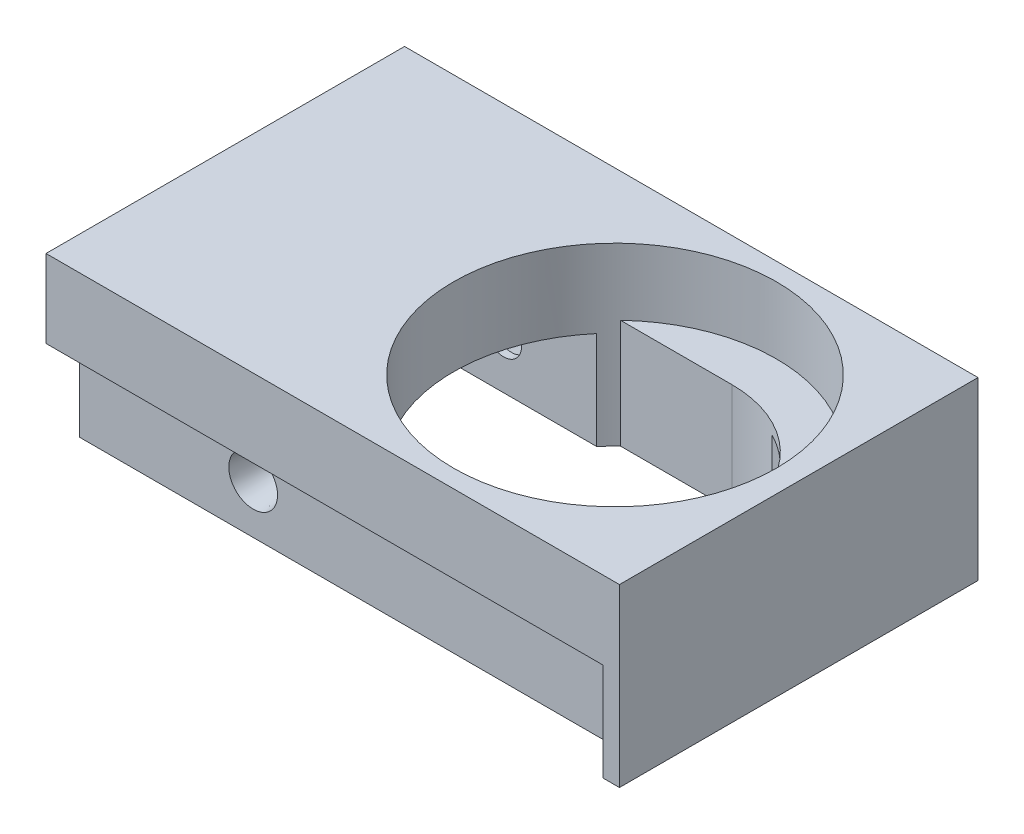
from build123d import *

# Parameters (mm, degrees)
SKETCH1_R               = 13.335
BOSS_EXTRUDE1_DEPTH     = 11.16076
SKETCH3_W               = 63.5
SKETCH3_H               = 40.894
SKETCH3_R               = 13.335
BOSS_EXTRUDE4_DEPTH     = 1.27
BOSS_EXTRUDE5_START     = 1.27
SKETCH2_W               = 63.5
SKETCH2_H               = 40.894
SKETCH2_R               = 18.415
BOSS_EXTRUDE5_DEPTH     = 3.81
SKETCH4_W               = 63.5
SKETCH4_H               = 23.876
CUT_EXTRUDE1_DEPTH      = 11.16076
SKETCH5_R               = 2.7813
CUT_EXTRUDE2_DEPTH      = 3.81
CUT_EXTRUDE2_DRAFT      = -8
SKETCH6_R               = 2.032
CUT_EXTRUDE3_DEPTH      = 49.774828153
MIRROR1_COPY_1_SKETCH_R = 2.7813
MIRROR1_COPY_1_DEPTH    = 3.81
MIRROR1_COPY_1_DRAFT    = -8
CUT_EXTRUDE4_DEPTH      = 40.757591768
SKETCH8_W               = 40.894
SKETCH8_H               = 16.24076
BOSS_EXTRUDE6_DEPTH     = 1.905
SKETCH9_W               = 65.405
SKETCH9_H               = 40.894
SKETCH9_R               = 18.415
BOSS_EXTRUDE8_DEPTH     = 3.81


with BuildPart() as part:
    # Sketch1 → Boss-Extrude1 (new body)
    with BuildSketch(Plane(origin=(0, 0, 0), x_dir=(1, 0, 0), z_dir=(0, 1, 0))):
        with BuildLine():
            Line((-31.75, 16.637), (-31.75, 12.192))
            Line((-31.75, 12.192), (2.53285876, 12.192))
            ThreePointArc((2.53285876, 12.192), (-3.175, 0), (2.53285876, -12.192))
            Line((2.53285876, -12.192), (-31.75, -12.192))
            Line((-31.75, -12.192), (-31.75, -16.637))
            Line((-31.75, -16.637), (31.75, -16.637))
            Line((31.75, -16.637), (31.75, -12.192))
            Line((31.75, -12.192), (22.86714124, -12.192))
            ThreePointArc((22.86714124, -12.192), (28.575, 0), (22.86714124, 12.192))
            Line((22.86714124, 12.192), (31.75, 12.192))
            Line((31.75, 12.192), (31.75, 16.637))
            Line((31.75, 16.637), (-31.75, 16.637))
        make_face()
        with Locations(Location((12.7, 0, 0), (0, 0, 270))):
            Circle(SKETCH1_R, mode=Mode.SUBTRACT)
        with BuildLine():
            Line((2.53285876, 12.192), (-31.75, 12.192))
            Line((-31.75, 12.192), (-31.75, -12.192))
            Line((-31.75, -12.192), (2.53285876, -12.192))
            ThreePointArc((2.53285876, -12.192), (-3.175, 0), (2.53285876, 12.192))
        make_face()
        with BuildLine():
            Line((31.75, -12.192), (31.75, 12.192))
            Line((31.75, 12.192), (22.86714124, 12.192))
            ThreePointArc((22.86714124, 12.192), (28.575, 0), (22.86714124, -12.192))
            Line((22.86714124, -12.192), (31.75, -12.192))
        make_face()
    extrude(amount=BOSS_EXTRUDE1_DEPTH)

    # Sketch3 → Boss-Extrude4 (add)
    with BuildSketch(Plane(origin=(0, 11.16076, 0), x_dir=(1, 0, 0), z_dir=(0, 1, 0))):
        Rectangle(SKETCH3_W, SKETCH3_H)
        with Locations(Location((12.7, 0, 0), (0, 0, 270))):
            Circle(SKETCH3_R, mode=Mode.SUBTRACT)
    extrude(amount=BOSS_EXTRUDE4_DEPTH)

    # Sketch2 → Boss-Extrude5 (add)
    with BuildSketch(Plane(origin=(0, 11.16076, 0), x_dir=(1, 0, 0), z_dir=(0, 1, 0)).offset(BOSS_EXTRUDE5_START)):
        Rectangle(SKETCH2_W, SKETCH2_H)
        with Locations(Location((12.7, 0, 0), (0, 0, 90))):
            Circle(SKETCH2_R, mode=Mode.SUBTRACT)
    extrude(amount=BOSS_EXTRUDE5_DEPTH)

    # Sketch4 → Cut-Extrude1 (cut)
    with BuildSketch(Plane.XZ):
        Rectangle(SKETCH4_W, SKETCH4_H)
    extrude(amount=-CUT_EXTRUDE1_DEPTH, mode=Mode.SUBTRACT)


with BuildPart() as cut_extrude2_tool:
    # Sketch5 → Cut-Extrude2 (with draft: the straight prism first)
    with BuildSketch(Plane(origin=(0, 0, -16.637), x_dir=(-1, 0, 0), z_dir=(0, 0, -1))):
        with Locations((11.93038, 5.58038)):
            Circle(SKETCH5_R)
    extrude(amount=-CUT_EXTRUDE2_DEPTH)
    # Cut-Extrude2: the draft: its side faces are tilted about the plane it starts from
    cut_extrude2_sides = [cut_extrude2_tool.faces().sort_by_distance(p)[0] for p in [
        (-9.14908, 5.58038, -14.732),
    ]]
    draft(cut_extrude2_sides, Plane(origin=(0, 0, -16.637), x_dir=(-1, 0, 0), z_dir=(0, 0, -1)), CUT_EXTRUDE2_DRAFT)


with BuildPart() as part_1:
    add(part.part)

    # Cut-Extrude2: cut by cut_extrude2_tool
    add(cut_extrude2_tool.part, mode=Mode.SUBTRACT)

    # Sketch6 → Cut-Extrude3 (cut, through all)
    with BuildSketch(Plane(origin=(0, 0, -12.827), x_dir=(-1, 0, 0), z_dir=(0, 0, -1))):
        with Locations((11.93038, 5.58038)):
            Circle(SKETCH6_R)
    extrude(amount=-CUT_EXTRUDE3_DEPTH, mode=Mode.SUBTRACT)


with BuildPart() as mirror1_copy_1_tool:
    # Mirror1 copy 1 sketch → Mirror1 copy 1 (with draft: the straight prism first)
    with BuildSketch(Plane(origin=(0, 0, 16.637), x_dir=(-1, 0, 0), z_dir=(0, 0, 1))):
        with Locations((11.93038, -5.58038)):
            Circle(MIRROR1_COPY_1_SKETCH_R)
    extrude(amount=-MIRROR1_COPY_1_DEPTH)
    # Mirror1 copy 1: the draft: its side faces are tilted about the plane it starts from
    mirror1_copy_1_sides = [mirror1_copy_1_tool.faces().sort_by_distance(p)[0] for p in [
        (-9.14908, 5.58038, 14.732),
    ]]
    draft(mirror1_copy_1_sides, Plane(origin=(0, 0, 16.637), x_dir=(-1, 0, 0), z_dir=(0, 0, 1)), MIRROR1_COPY_1_DRAFT)


with BuildPart() as part_2:
    add(part_1.part)

    # Mirror1 copy 1: cut by mirror1_copy_1_tool
    add(mirror1_copy_1_tool.part, mode=Mode.SUBTRACT)

    # Sketch7 → Cut-Extrude4 (cut, through all)
    with BuildSketch(Plane(origin=(0, 12.43076, 0), x_dir=(1, 0, 0), z_dir=(0, 1, 0))):
        with BuildLine():
            Line((12.7, 13.335), (0, 13.335))
            ThreePointArc((0, 13.335), (-5.715, 0), (0, -13.335))
            Line((0, -13.335), (12.7, -13.335))
            ThreePointArc((12.7, -13.335), (-0.635, 0), (12.7, 13.335))
        make_face()
    extrude(amount=-CUT_EXTRUDE4_DEPTH, mode=Mode.SUBTRACT)

    # Sketch8 → Boss-Extrude6 (add)
    with BuildSketch(Plane(origin=(31.75, 0, 0), x_dir=(0, 0, -1), z_dir=(1, 0, 0))):
        with Locations((0, 8.12038)):
            Rectangle(SKETCH8_W, SKETCH8_H)
    extrude(amount=BOSS_EXTRUDE6_DEPTH)

    # Sketch9 → Boss-Extrude8 (add)
    with BuildSketch(Plane(origin=(0, 16.24076, 0), x_dir=(1, 0, 0), z_dir=(0, 1, 0))):
        with Locations((0.9525, 0)):
            Rectangle(SKETCH9_W, SKETCH9_H)
        with Locations(Location((12.7, 0, 0), (0, 0, 133.602818973))):
            Circle(SKETCH9_R, mode=Mode.SUBTRACT)
    extrude(amount=BOSS_EXTRUDE8_DEPTH)


solid = part_2.part
